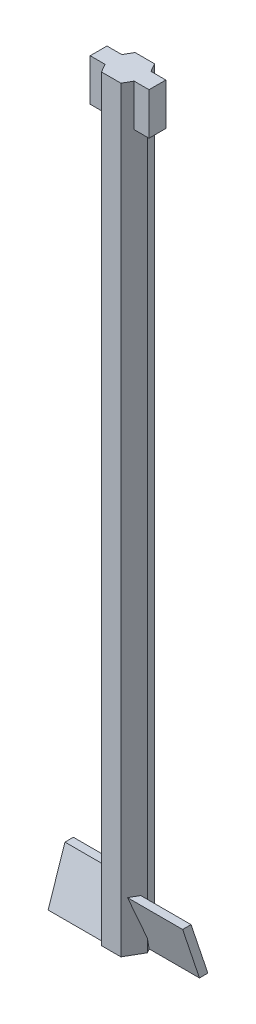
from build123d import *

# Parameters (mm, degrees)
BOSS_EXTRUDE1_DEPTH = 90
SKETCH2_W           = 7
SKETCH2_H           = 2
BOSS_EXTRUDE2_DEPTH = 5
BOSS_EXTRUDE3_DEPTH = 8
BOSS_EXTRUDE4_DEPTH = 8


with BuildPart() as part:
    # Sketch1 → Boss-Extrude1 (new body)
    with BuildSketch(Plane(origin=(0, 0, 0), x_dir=(1, 0, 0), z_dir=(0, 1, 0))):
        Polygon((-1.154700538, 2), (-2.309401077, 0), (-1.154700538, -2), (1.154700538, -2), (2.309401077, 0), (1.154700538, 2), align=None)
    extrude(amount=BOSS_EXTRUDE1_DEPTH)

    # Sketch2 → Boss-Extrude2 (add)
    with BuildSketch(Plane(origin=(0, 90, 0), x_dir=(1, 0, 0), z_dir=(0, 1, 0))):
        Rectangle(SKETCH2_W, SKETCH2_H)
    extrude(amount=-BOSS_EXTRUDE2_DEPTH)

    # Sketch3 → Boss-Extrude3 (add)
    with BuildSketch(Plane(origin=(0, 0, 0), x_dir=(0, 0, -1), z_dir=(1, 0, 0))):
        Polygon((-1.5, 6), (-0.5, 6), (1.5, 0), (0.5, 0), align=None)
    extrude(amount=BOSS_EXTRUDE3_DEPTH)

    # Sketch4 → Boss-Extrude4 (add)
    with BuildSketch(Plane(origin=(0, 0, 0), x_dir=(0, 0, -1), z_dir=(1, 0, 0))):
        Polygon((1.5, 6), (0.5, 6), (-1.5, 0), (-0.5, 0), align=None)
    extrude(amount=-BOSS_EXTRUDE4_DEPTH)


solid = part.part
